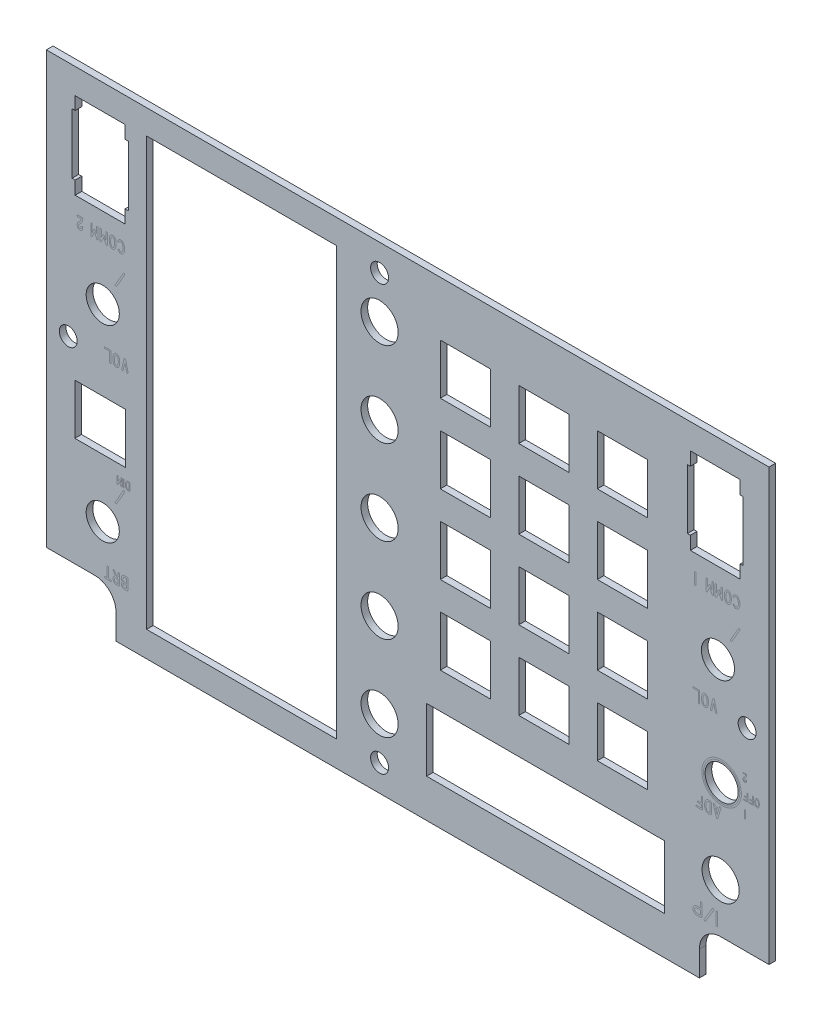
from build123d import *

# Parameters (mm, degrees)
BOSS_EXTRUDE1_DEPTH   = 1.5875
SKETCH3_R             = 4.445
SKETCH3_W             = 12.065
SKETCH3_H             = 12.065
CUT_EXTRUDE1_DEPTH    = 2.5875
SKETCH4_R             = 3.96875
CUT_EXTRUDE2_DEPTH    = 2.5875
SKETCH5_W             = 11.94
SKETCH5_H             = 20.64
SKETCH5_W_2           = 45.462
SKETCH5_H_2           = 102.32
SKETCH5_W_3           = 57
SKETCH5_H_3           = 15.1
CUT_EXTRUDE3_DEPTH    = 2.5875
F_6_CLEARANCE_HOLE2_D = 4.3053
CUT_EXTRUDE4_START    = -1.5875
SKETCH11_W            = 13.529020254
SKETCH11_H            = 14.424558238
SKETCH11_W_2          = 13.332833864
SKETCH11_H_2          = 14.312726797
CUT_EXTRUDE4_DEPTH    = 1.5875


with BuildPart() as part:
    # Sketch1 → Boss-Extrude1 (new body)
    with BuildSketch(Plane.XY):
        with BuildLine():
            Line((74.93, -171.1167297), (86.51875, -171.1167297))
            Line((86.51875, -171.1167297), (86.51875, -67.9292297))
            Line((86.51875, -67.9292297), (-86.51875, -67.9292297))
            Line((-86.51875, -67.9292297), (-86.51875, -171.1167297))
            Line((-86.51875, -171.1167297), (-74.93, -171.1167297))
            ThreePointArc((-74.93, -171.1167297), (-71.337897552, -172.604627251), (-69.85, -176.1967297))
            Line((-69.85, -176.1967297), (-69.85, -182.2292297))
            Line((-69.85, -182.2292297), (69.85, -182.2292297))
            Line((69.85, -182.2292297), (69.85, -176.1967297))
            ThreePointArc((69.85, -176.1967297), (71.337897552, -172.604627251), (74.93, -171.1167297))
        make_face()
    extrude(amount=-BOSS_EXTRUDE1_DEPTH)

    # Sketch3 → Cut-Extrude1 (cut, through all)
    with BuildSketch(Plane.XY):
        with Locations((74.93, -159.3692297)):
            Circle(SKETCH3_R)
        with Locations((-6.731, -165.7192297)):
            Circle(SKETCH3_R)
        with Locations((-6.731, -145.3992297)):
            Circle(SKETCH3_R)
        with Locations((-6.731, -125.0792297)):
            Circle(SKETCH3_R)
        with Locations((-6.731, -104.7592297)):
            Circle(SKETCH3_R)
        with Locations((-6.731, -84.4392297)):
            Circle(SKETCH3_R)
        with Locations((-73.66, -139.0492297)):
            Rectangle(SKETCH3_W, SKETCH3_H)
        with Locations((13.843, -143.3672297)):
            Rectangle(SKETCH3_W, SKETCH3_H)
        with Locations((32.639, -143.3672297)):
            Rectangle(SKETCH3_W, SKETCH3_H)
        with Locations((51.435, -143.3672297)):
            Rectangle(SKETCH3_W, SKETCH3_H)
        with Locations((51.435, -124.5712297)):
            Rectangle(SKETCH3_W, SKETCH3_H)
        with Locations((32.639, -124.5712297)):
            Rectangle(SKETCH3_W, SKETCH3_H)
        with Locations((13.843, -124.5712297)):
            Rectangle(SKETCH3_W, SKETCH3_H)
        with Locations((13.843, -105.7752297)):
            Rectangle(SKETCH3_W, SKETCH3_H)
        with Locations((13.843, -86.9792297)):
            Rectangle(SKETCH3_W, SKETCH3_H)
        with Locations((32.639, -86.9792297)):
            Rectangle(SKETCH3_W, SKETCH3_H)
        with Locations((32.639, -105.7752297)):
            Rectangle(SKETCH3_W, SKETCH3_H)
        with Locations((51.435, -105.7752297)):
            Rectangle(SKETCH3_W, SKETCH3_H)
        with Locations((51.435, -86.9792297)):
            Rectangle(SKETCH3_W, SKETCH3_H)
    extrude(amount=-CUT_EXTRUDE1_DEPTH, mode=Mode.SUBTRACT)

    # Sketch4 → Cut-Extrude2 (cut, through all)
    with BuildSketch(Plane.XY):
        with Locations((-73.025, -113.9667297)):
            Circle(SKETCH4_R)
        with Locations((-73.025, -159.0517297)):
            Circle(SKETCH4_R)
        with Locations((74.295, -113.9667297)):
            Circle(SKETCH4_R)
        with Locations((75.184, -139.0492297)):
            Circle(SKETCH4_R)
    extrude(amount=-CUT_EXTRUDE2_DEPTH, mode=Mode.SUBTRACT)

    # Sketch5 → Cut-Extrude3 (cut, through all)
    with BuildSketch(Plane.XY):
        with Locations((-73.66, -84.3122297)):
            Rectangle(SKETCH5_W, SKETCH5_H)
        with Locations((73.66, -84.3122297)):
            Rectangle(SKETCH5_W, SKETCH5_H)
        with Locations((-39.799, -124.9522297)):
            Rectangle(SKETCH5_W_2, SKETCH5_H_2)
        with Locations((33.02, -165.4922297)):
            Rectangle(SKETCH5_W_3, SKETCH5_H_3)
    extrude(amount=-CUT_EXTRUDE3_DEPTH, mode=Mode.SUBTRACT)

    # #6 Clearance Hole2 (through all)
    with Locations(Plane(origin=(0, 0, 0), x_dir=(-1, 0, 0), z_dir=(0, 0, 1))):
        with Locations((-81.28, 124.6982297), (6.731, 175.8792297), (81.28, 124.6982297), (6.731, 74.2792297)):
            Hole(F_6_CLEARANCE_HOLE2_D / 2)

    # Sketch11 → Cut-Extrude4 (cut)
    with BuildSketch(Plane(origin=(0, 0, -1.5875), x_dir=(-1, 0, 0), z_dir=(0, 0, -1)).offset(CUT_EXTRUDE4_START)):
        with Locations((73.612537257, -84.279184845)):
            Rectangle(SKETCH11_W, SKETCH11_H)
        with Locations((-73.648214967, -84.336507402)):
            Rectangle(SKETCH11_W_2, SKETCH11_H_2)
    extrude(amount=CUT_EXTRUDE4_DEPTH, mode=Mode.SUBTRACT)


solid = part.part
